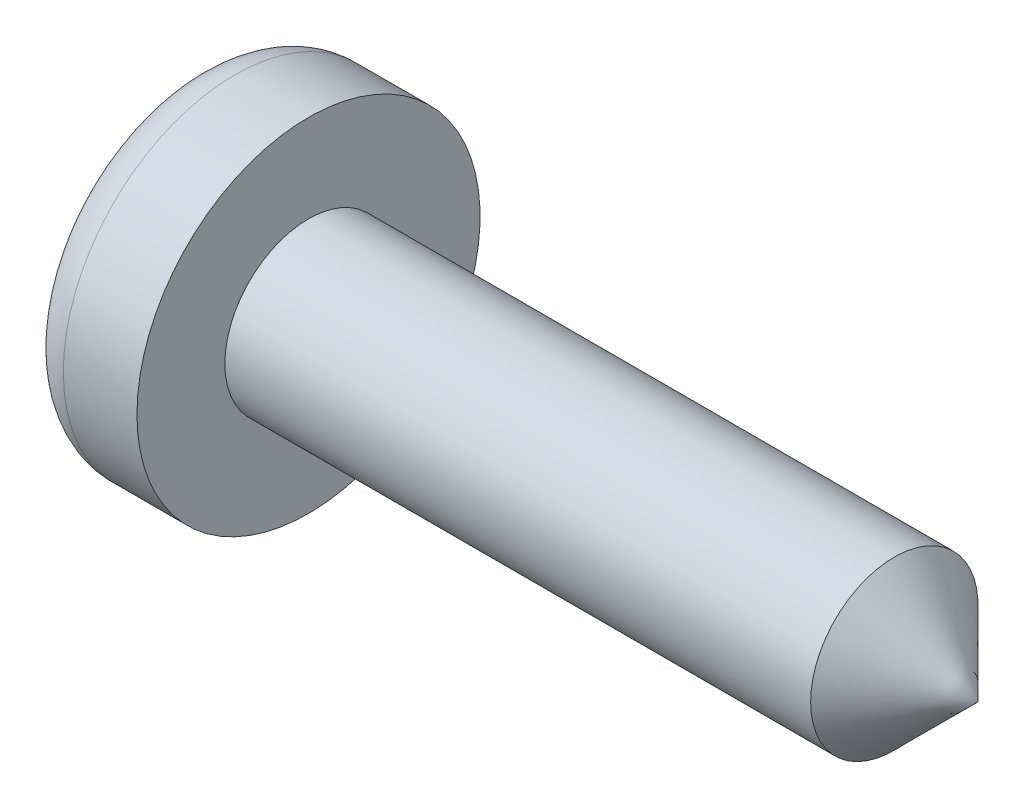
from build123d import *

# Parameters (mm, degrees)
CUT_EXTRUDE_1_DEPTH = 0.5
FILLET_1_R          = 0.5


with BuildPart() as part:
    # 草图1 → 旋转1 (revolve)
    with BuildSketch(Plane.XY):
        Polygon((0, 0), (0, 2.05), (1.38, 2.05), (1.38, 1), (8.38, 1), (9.38, 0), align=None)
    revolve(axis=Axis((-6.976540153, 0, 0), (1, 0, 0)))

    # 草图2 → 切除-拉伸1 (cut)
    with BuildSketch(Plane.ZY):
        Polygon((-0.3, 0.3), (-1, 0.3), (-1, -0.3), (-0.3, -0.3), (-0.3, -1), (0.3, -1), (0.3, -0.3), (1, -0.3), (1, 0.3), (0.3, 0.3), (0.3, 1), (-0.3, 1), align=None)
    extrude(amount=-CUT_EXTRUDE_1_DEPTH, mode=Mode.SUBTRACT)

    # 圆角1
    fillet_1_edges = [part.edges().sort_by_distance(p)[0] for p in [
        (0, -2.05, 0),
    ]]
    fillet(fillet_1_edges, radius=FILLET_1_R)


solid = part.part
